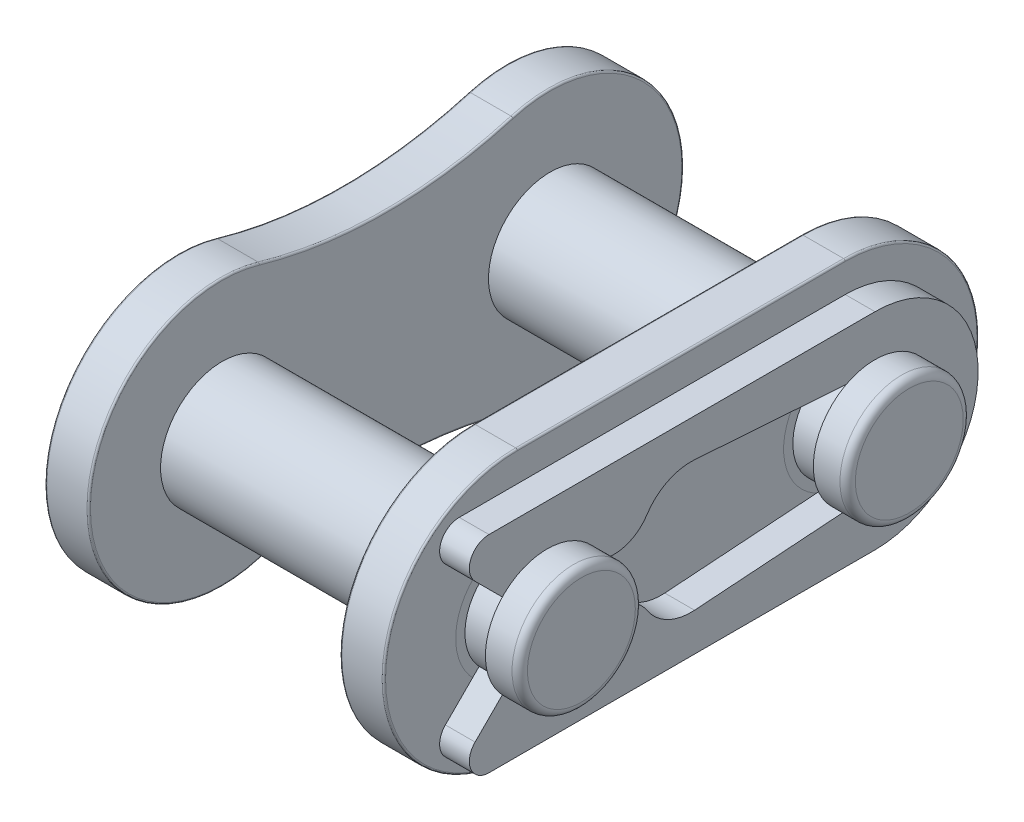
from build123d import *

# Parameters (mm, degrees)
BOSS_EXTRUDE1_START        = 3.65125
SKETCH3_R                  = 1.7907
BOSS_EXTRUDE1_DEPTH        = 1.27
FILLET1_R                  = 0.0508
BOSS_EXTRUDE2_START        = -3.65125
SKETCH4_R                  = 1.7907
BOSS_EXTRUDE2_DEPTH        = 1.27
FILLET2_R                  = 0.0508
SKETCH5_R                  = 1.7907
BOSS_EXTRUDE3_DEPTH        = 6.7818
BOSS_EXTRUDE3_DEPTH_BACK   = 5.9182
BOSS_EXTRUDE3_2_DEPTH      = 6.7818
BOSS_EXTRUDE3_2_DEPTH_BACK = 5.9182
FILLET3_R                  = 0.447675
FILLET4_R                  = 0.447675
BOSS_EXTRUDE4_DEPTH        = 0.8636
SKETCH8_R                  = 1.7907
SKETCH8_R_2                = 1.522095
CUT_EXTRUDE1_DEPTH         = 0.8636
SKETCH9_R                  = 1.7907
SKETCH9_R_2                = 1.522095
CUT_EXTRUDE2_DEPTH         = 0.8636
FILLET5_R                  = 0.2238375
FILLET6_R                  = 0.2238375


with BuildPart() as part:
    # Sketch3 → Boss-Extrude1 (new body)
    with BuildSketch(Plane(origin=(0, 0, 0), x_dir=(0, 0, -1), z_dir=(1, 0, 0)).offset(BOSS_EXTRUDE1_START)):
        with BuildLine():
            Line((-4.7625, 3.878072), (4.7625, 3.878072))
            ThreePointArc((4.7625, 3.878072), (8.640572, 0), (4.7625, -3.878072))
            Line((4.7625, -3.878072), (-4.7625, -3.878072))
            ThreePointArc((-4.7625, -3.878072), (-8.640572, 0), (-4.7625, 3.878072))
        make_face()
        with Locations((-4.7625, 0)):
            Circle(SKETCH3_R, mode=Mode.SUBTRACT)
        with Locations((4.7625, 0)):
            Circle(SKETCH3_R, mode=Mode.SUBTRACT)
    extrude(amount=BOSS_EXTRUDE1_DEPTH)

    # Fillet1
    fillet1_edges = [part.edges().sort_by_distance(p)[0] for p in [
        (4.92125, 0, -8.640572),
        (4.92125, 3.878072, 0),
        (4.92125, 0, 8.640572),
        (3.65125, 3.878072, 0),
        (3.65125, 0, -8.640572),
        (3.65125, -3.878072, 0),
        (3.65125, 0, 8.640572),
        (4.92125, -3.878072, 0),
    ]]
    fillet(fillet1_edges, radius=FILLET1_R)


with BuildPart() as body_2:
    # Sketch4 → Boss-Extrude2 (new body)
    with BuildSketch(Plane(origin=(0, 0, 0), x_dir=(0, 0, -1), z_dir=(1, 0, 0)).offset(BOSS_EXTRUDE2_START)):
        with BuildLine():
            ThreePointArc((-3.673357527, 3.721990208), (-8.640572, 0), (-3.673357527, -3.721990208))
            ThreePointArc((-3.673357527, -3.721990208), (0, -3.195572188), (3.673357527, -3.721990208))
            ThreePointArc((3.673357527, -3.721990208), (8.640572, 0), (3.673357527, 3.721990208))
            ThreePointArc((3.673357527, 3.721990208), (0, 3.195572188), (-3.673357527, 3.721990208))
        make_face()
        with Locations((-4.7625, 0)):
            Circle(SKETCH4_R, mode=Mode.SUBTRACT)
        with Locations((4.7625, 0)):
            Circle(SKETCH4_R, mode=Mode.SUBTRACT)
    extrude(amount=-BOSS_EXTRUDE2_DEPTH)

    # Fillet2
    fillet2_edges = [body_2.edges().sort_by_distance(p)[0] for p in [
        (-4.92125, -3.195572188, 0),
        (-4.92125, 0, -8.640572),
        (-4.92125, 3.195572188, 0),
        (-3.65125, 0, -8.640572),
        (-3.65125, -3.195572188, 0),
        (-3.65125, 0, 8.640572),
        (-3.65125, 3.195572188, 0),
        (-4.92125, 0, 8.640572),
    ]]
    fillet(fillet2_edges, radius=FILLET2_R)


with BuildPart() as body_3:
    # Sketch5 → Boss-Extrude3 (new body, two sides)
    with BuildSketch(Plane(origin=(0, 0, 0), x_dir=(0, 0, -1), z_dir=(1, 0, 0))) as boss_extrude3_sk:
        with Locations((-4.7625, 0)):
            Circle(SKETCH5_R)
    extrude(amount=BOSS_EXTRUDE3_DEPTH)
    extrude(boss_extrude3_sk.sketch, amount=-BOSS_EXTRUDE3_DEPTH_BACK)

    # Fillet3
    fillet3_edges = [body_3.edges().sort_by_distance(p)[0] for p in [
        (-5.9182, 0, 6.5532),
    ]]
    fillet(fillet3_edges, radius=FILLET3_R)

    # Sketch8 → Cut-Extrude1 (cut)
    with BuildSketch(Plane(origin=(4.92125, 0, 0), x_dir=(0, 0, -1), z_dir=(1, 0, 0))):
        with Locations((-4.7625, 0)):
            Circle(SKETCH8_R)
        with Locations((-4.7625, 0)):
            Circle(SKETCH8_R_2, mode=Mode.SUBTRACT)
    extrude(amount=CUT_EXTRUDE1_DEPTH, mode=Mode.SUBTRACT)

    # Fillet5
    fillet5_edges = [body_3.edges().sort_by_distance(p)[0] for p in [
        (6.7818, 0, 6.5532),
    ]]
    fillet(fillet5_edges, radius=FILLET5_R)


with BuildPart() as body_4:
    # Sketch5 → Boss-Extrude3 2 (new body, two sides)
    with BuildSketch(Plane(origin=(0, 0, 0), x_dir=(0, 0, -1), z_dir=(1, 0, 0))) as boss_extrude3_2_sk:
        with Locations((4.7625, 0)):
            Circle(SKETCH5_R)
    extrude(amount=BOSS_EXTRUDE3_2_DEPTH)
    extrude(boss_extrude3_2_sk.sketch, amount=-BOSS_EXTRUDE3_2_DEPTH_BACK)

    # Fillet4
    fillet4_edges = [body_4.edges().sort_by_distance(p)[0] for p in [
        (-5.9182, 0, -2.9718),
    ]]
    fillet(fillet4_edges, radius=FILLET4_R)

    # Sketch9 → Cut-Extrude2 (cut)
    with BuildSketch(Plane(origin=(4.92125, 0, 0), x_dir=(0, 0, -1), z_dir=(1, 0, 0))):
        with Locations((4.7625, 0)):
            Circle(SKETCH9_R)
        with Locations((4.7625, 0)):
            Circle(SKETCH9_R_2, mode=Mode.SUBTRACT)
    extrude(amount=CUT_EXTRUDE2_DEPTH, mode=Mode.SUBTRACT)

    # Fillet6
    fillet6_edges = [body_4.edges().sort_by_distance(p)[0] for p in [
        (6.7818, 0, -2.9718),
    ]]
    fillet(fillet6_edges, radius=FILLET6_R)


with BuildPart() as body_5:
    # Sketch7 → Boss-Extrude4 (new body)
    with BuildSketch(Plane(origin=(4.92125, 0, 0), x_dir=(0, 0, -1), z_dir=(1, 0, 0))):
        with BuildLine():
            Line((4.7625, -2.996692), (-6.449341275, -2.996692))
            ThreePointArc((-6.449341275, -2.996692), (-6.976678431, -2.644336577), (-6.852947661, -2.022299989))
            Line((-6.852947661, -2.022299989), (-5.872318029, -1.041670357))
            ThreePointArc((-5.872318029, -1.041670357), (-4.7625, -1.522095), (-3.652681971, -1.041670357))
            ThreePointArc((-3.652681971, -1.041670357), (-2.718531649, -0.685898777), (-1.862425825, -1.201934688))
            ThreePointArc((-1.862425825, -1.201934688), (-1.264928618, -1.735857104), (-0.479059679, -1.892337359))
            Line((-0.479059679, -1.892337359), (4.86867598, -1.518387253))
            ThreePointArc((4.86867598, -1.518387253), (6.284595, 0), (4.86867598, 1.518387253))
            Line((4.86867598, 1.518387253), (-0.479059679, 1.892337359))
            ThreePointArc((-0.479059679, 1.892337359), (-1.264928618, 1.735857104), (-1.862425825, 1.201934688))
            ThreePointArc((-1.862425825, 1.201934688), (-2.718531649, 0.685898777), (-3.652681971, 1.041670357))
            ThreePointArc((-3.652681971, 1.041670357), (-4.7625, 1.522095), (-5.872318029, 1.041670357))
            Line((-5.872318029, 1.041670357), (-6.852947661, 2.022299989))
            ThreePointArc((-6.852947661, 2.022299989), (-6.976678431, 2.644336577), (-6.449341275, 2.996692))
            Line((-6.449341275, 2.996692), (4.7625, 2.996692))
            ThreePointArc((4.7625, 2.996692), (7.759192, 0), (4.7625, -2.996692))
        make_face()
    extrude(amount=BOSS_EXTRUDE4_DEPTH)


solid = Compound([part.part, body_2.part, body_3.part, body_4.part, body_5.part])
